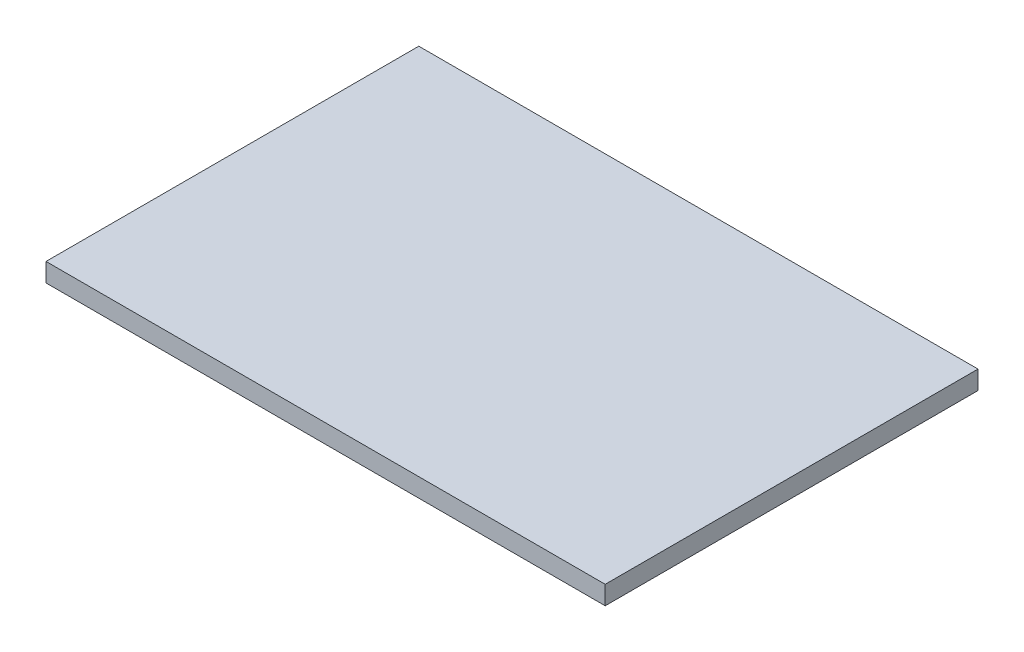
from build123d import *

# Parameters (mm, degrees)
SKETCH2_W           = 100
SKETCH2_H           = 5
BOSS_EXTRUDE1_DEPTH = 150


with BuildPart() as part:
    # Sketch2 → Boss-Extrude1 (new body)
    with BuildSketch(Plane(origin=(0, 0, 0), x_dir=(0, 0, -1), z_dir=(1, 0, 0))):
        with Locations((-50, 2.5)):
            Rectangle(SKETCH2_W, SKETCH2_H)
    extrude(amount=-BOSS_EXTRUDE1_DEPTH)


solid = part.part
